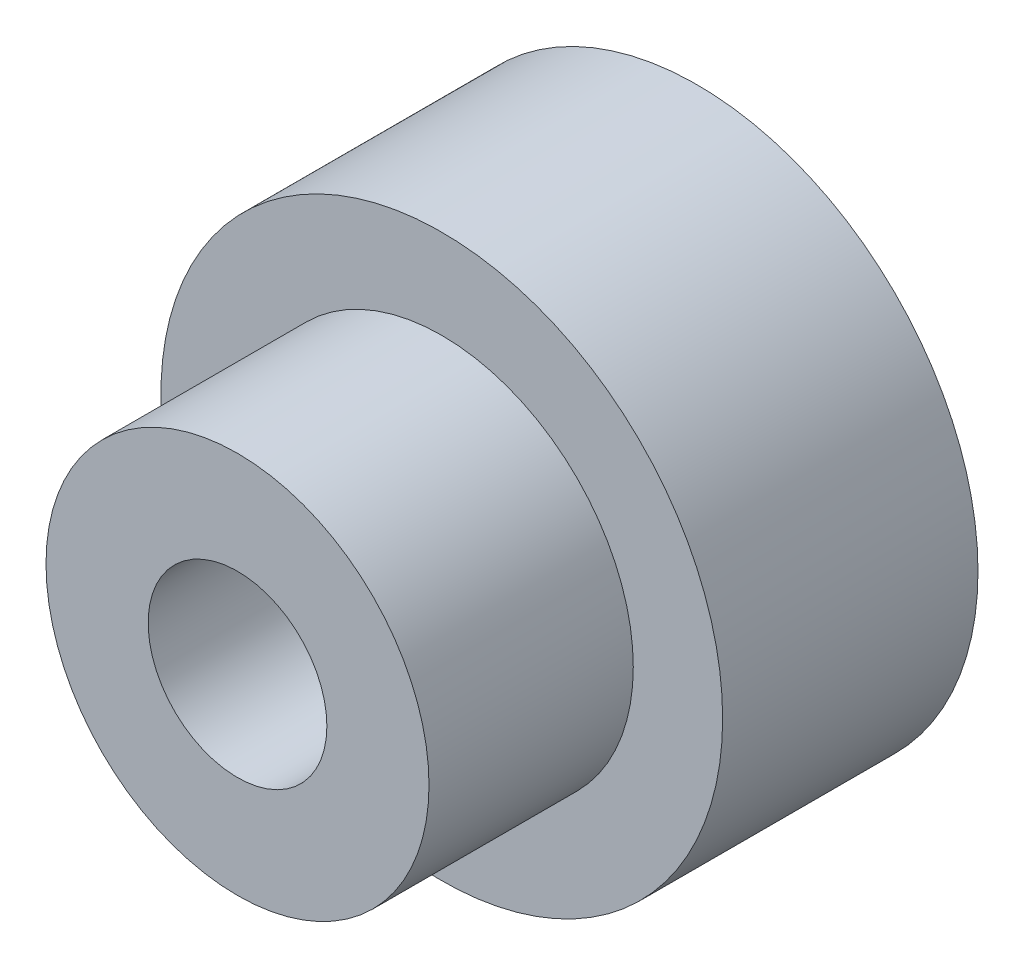
from build123d import *

# Parameters (mm, degrees)
SKETCH_1_R          = 11
EXTRUDE_1_DEPTH     = 10
SKETCH_2_R          = 7.5
EXTRUDE_2_DEPTH     = 8
SKETCH_3_R          = 3.5
CUT_EXTRUDE_1_DEPTH = 19


with BuildPart() as part:
    # 草图1 → 凸台-拉伸1 (new body)
    with BuildSketch(Plane.XY):
        Circle(SKETCH_1_R)
    extrude(amount=EXTRUDE_1_DEPTH)

    # 草图2 → 凸台-拉伸2 (add)
    with BuildSketch(Plane.XY.offset(10)):
        Circle(SKETCH_2_R)
    extrude(amount=EXTRUDE_2_DEPTH)

    # 草图3 → 切除-拉伸1 (cut, through all)
    with BuildSketch(Plane.XY.offset(18)):
        Circle(SKETCH_3_R)
    extrude(amount=-CUT_EXTRUDE_1_DEPTH, mode=Mode.SUBTRACT)


solid = part.part
